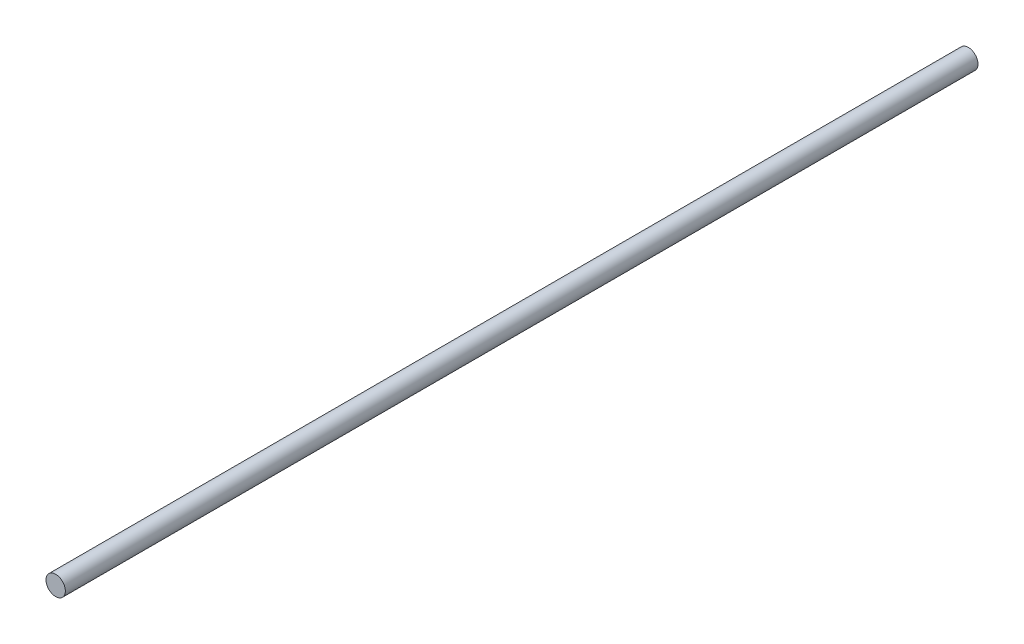
from build123d import *

# Parameters (mm, degrees)
SKETCH1_R           = 3
BOSS_EXTRUDE1_DEPTH = 141.25


with BuildPart() as part:
    # Sketch1 → Boss-Extrude1 (new body, symmetric)
    with BuildSketch(Plane.XY):
        Circle(SKETCH1_R)
    extrude(amount=BOSS_EXTRUDE1_DEPTH, both=True)


solid = part.part
